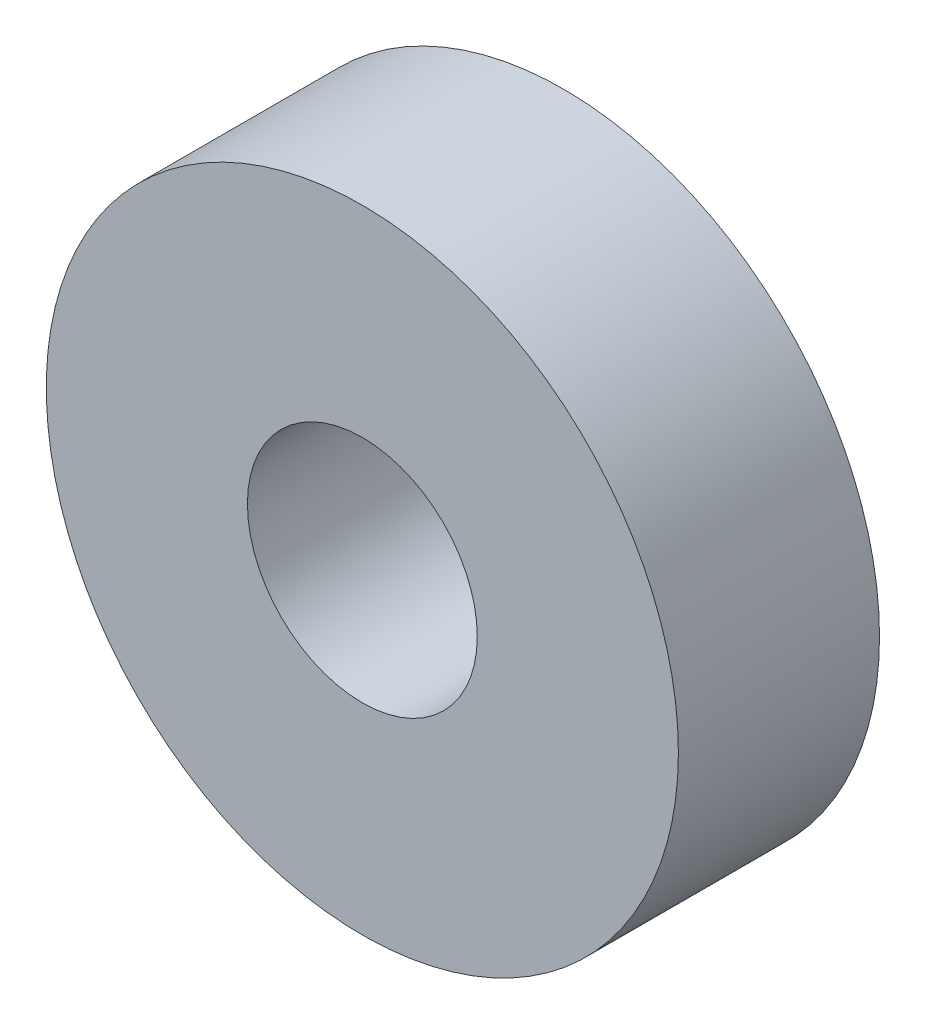
from build123d import *

# Parameters (mm, degrees)
ESBO_O1_R                  = 11
RESSALTO_EXTRUS_O1_DEPTH   = 7
ESBO_O2_R                  = 4
CORTE_EXTRUS_O1_DEPTH      = 1
CORTE_EXTRUS_O1_DEPTH_BACK = 8


with BuildPart() as part:
    # Esboço1 → Ressalto-extrusão1 (new body)
    with BuildSketch(Plane.XY):
        Circle(ESBO_O1_R)
    extrude(amount=RESSALTO_EXTRUS_O1_DEPTH)

    # Esboço2 → Corte-extrusão1 (cut, two sides)
    with BuildSketch(Plane.XY.offset(7)) as corte_extrus_o1_sk:
        Circle(ESBO_O2_R)
    extrude(amount=CORTE_EXTRUS_O1_DEPTH, mode=Mode.SUBTRACT)
    extrude(corte_extrus_o1_sk.sketch, amount=-CORTE_EXTRUS_O1_DEPTH_BACK, mode=Mode.SUBTRACT)


solid = part.part
